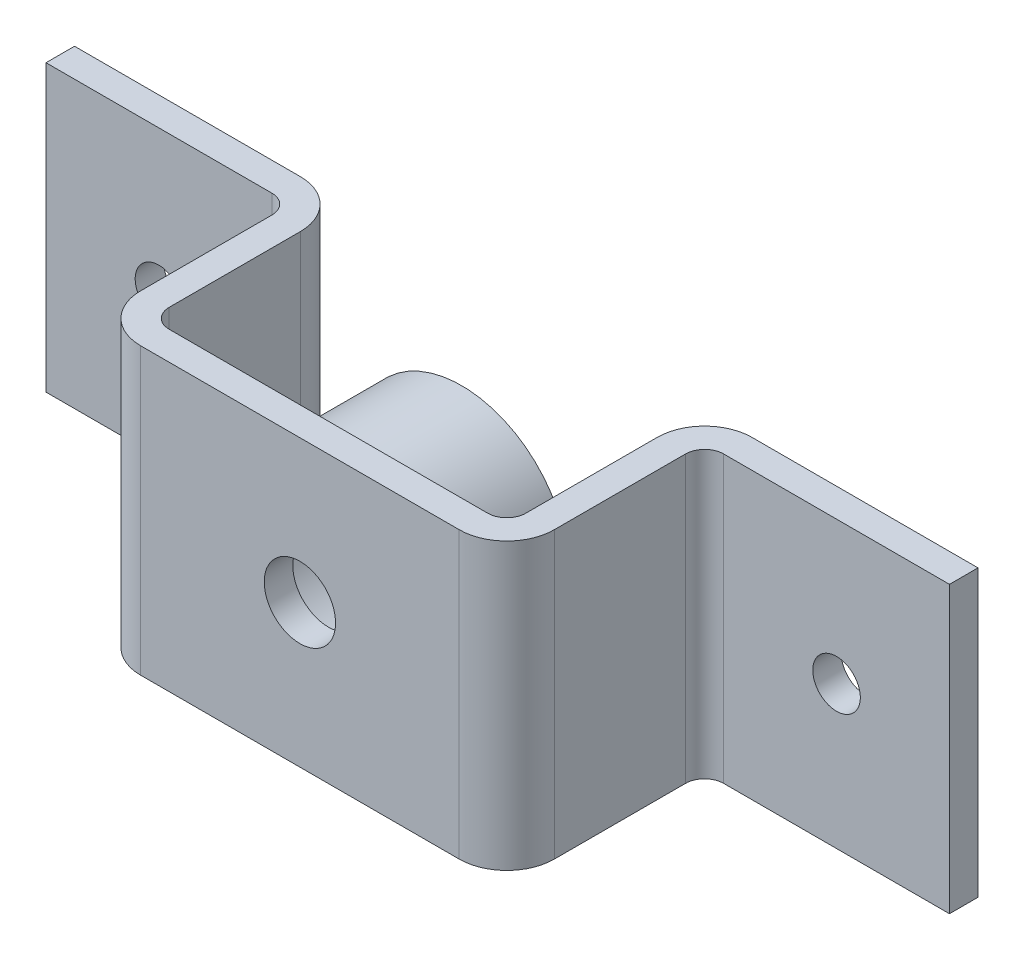
from build123d import *

# Parameters (mm, degrees)
SKETCH1_W           = 950
SKETCH1_H           = 300
BOSS_EXTRUDE1_DEPTH = 238
SKETCH2_W           = 375
SKETCH2_H           = 208
CUT_EXTRUDE1_DEPTH  = 305
SKETCH3_W           = 257.5
SKETCH3_H           = 208
CUT_EXTRUDE2_DEPTH  = 305
FILLET2_R           = 20
FILLET3_R           = 50
SKETCH4_R           = 112.5
SKETCH4_R_2         = 87.5
BOSS_EXTRUDE2_DEPTH = 140
SKETCH5_R           = 37.5
CUT_EXTRUDE3_DEPTH  = 75
SKETCH6_R           = 25
CUT_EXTRUDE4_DEPTH  = 39


with BuildPart() as part:
    # Sketch1 → Boss-Extrude1 (new body)
    with BuildSketch(Plane.XY):
        Rectangle(SKETCH1_W, SKETCH1_H)
    extrude(amount=-BOSS_EXTRUDE1_DEPTH)

    # Sketch2 → Cut-Extrude1 (cut)
    with BuildSketch(Plane(origin=(0, 150, 0), x_dir=(1, 0, 0), z_dir=(0, 1, 0))):
        with Locations((0, 134)):
            Rectangle(SKETCH2_W, SKETCH2_H)
    extrude(amount=-CUT_EXTRUDE1_DEPTH, mode=Mode.SUBTRACT)

    # Sketch3 → Cut-Extrude2 (cut)
    with BuildSketch(Plane.XZ.offset(150)):
        with Locations((346.25, -104)):
            Rectangle(SKETCH3_W, SKETCH3_H)
        with Locations((-346.25, -104)):
            Rectangle(SKETCH3_W, SKETCH3_H)
    extrude(amount=-CUT_EXTRUDE2_DEPTH, mode=Mode.SUBTRACT)

    # Fillet2
    fillet2_edges = [part.edges().sort_by_distance(p)[0] for p in [
        (187.5, 0, -30),
        (-187.5, 0, -30),
        (217.5, 0, -208),
        (-217.5, 0, -208),
    ]]
    fillet(fillet2_edges, radius=FILLET2_R)

    # Fillet3
    fillet3_edges = [part.edges().sort_by_distance(p)[0] for p in [
        (-187.5, 0, -238),
        (187.5, 0, -238),
        (217.5, 0, 0),
        (-217.5, 0, 0),
    ]]
    fillet(fillet3_edges, radius=FILLET3_R)

    # Sketch4 → Boss-Extrude2 (add)
    with BuildSketch(Plane(origin=(0, 0, -30), x_dir=(-1, 0, 0), z_dir=(0, 0, -1))):
        Circle(SKETCH4_R)
        Circle(SKETCH4_R_2, mode=Mode.SUBTRACT)
    extrude(amount=BOSS_EXTRUDE2_DEPTH)

    # Sketch5 → Cut-Extrude3 (cut)
    with BuildSketch(Plane(origin=(0, 0, -30), x_dir=(-1, 0, 0), z_dir=(0, 0, -1))):
        Circle(SKETCH5_R)
    extrude(amount=-CUT_EXTRUDE3_DEPTH, mode=Mode.SUBTRACT)

    # Sketch6 → Cut-Extrude4 (cut)
    with BuildSketch(Plane(origin=(0, 0, -238), x_dir=(-1, 0, 0), z_dir=(0, 0, -1))):
        with Locations((-356.25, 0)):
            Circle(SKETCH6_R)
    cut_extrude4 = extrude(amount=-CUT_EXTRUDE4_DEPTH, mode=Mode.SUBTRACT)

    # Mirror1: Cut-Extrude4 across plane
    add(cut_extrude4.mirror(Plane(origin=(0, 0, 0), x_dir=(0, 0, 1), z_dir=(1, 0, 0))), mode=Mode.SUBTRACT)


solid = part.part
